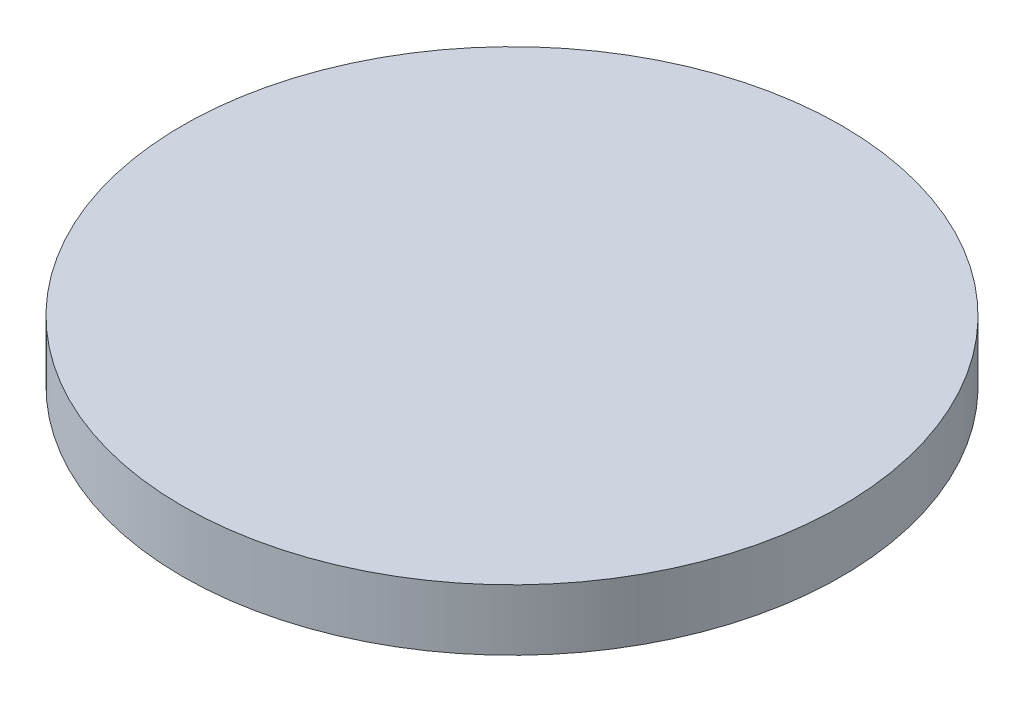
from build123d import *

# Parameters (mm, degrees)
SKETCH1_R           = 27
BOSS_EXTRUDE1_DEPTH = 5


with BuildPart() as part:
    # Sketch1 → Boss-Extrude1 (new body)
    with BuildSketch(Plane(origin=(0, 0, 0), x_dir=(1, 0, 0), z_dir=(0, 1, 0))):
        Circle(SKETCH1_R)
    extrude(amount=BOSS_EXTRUDE1_DEPTH)


solid = part.part
